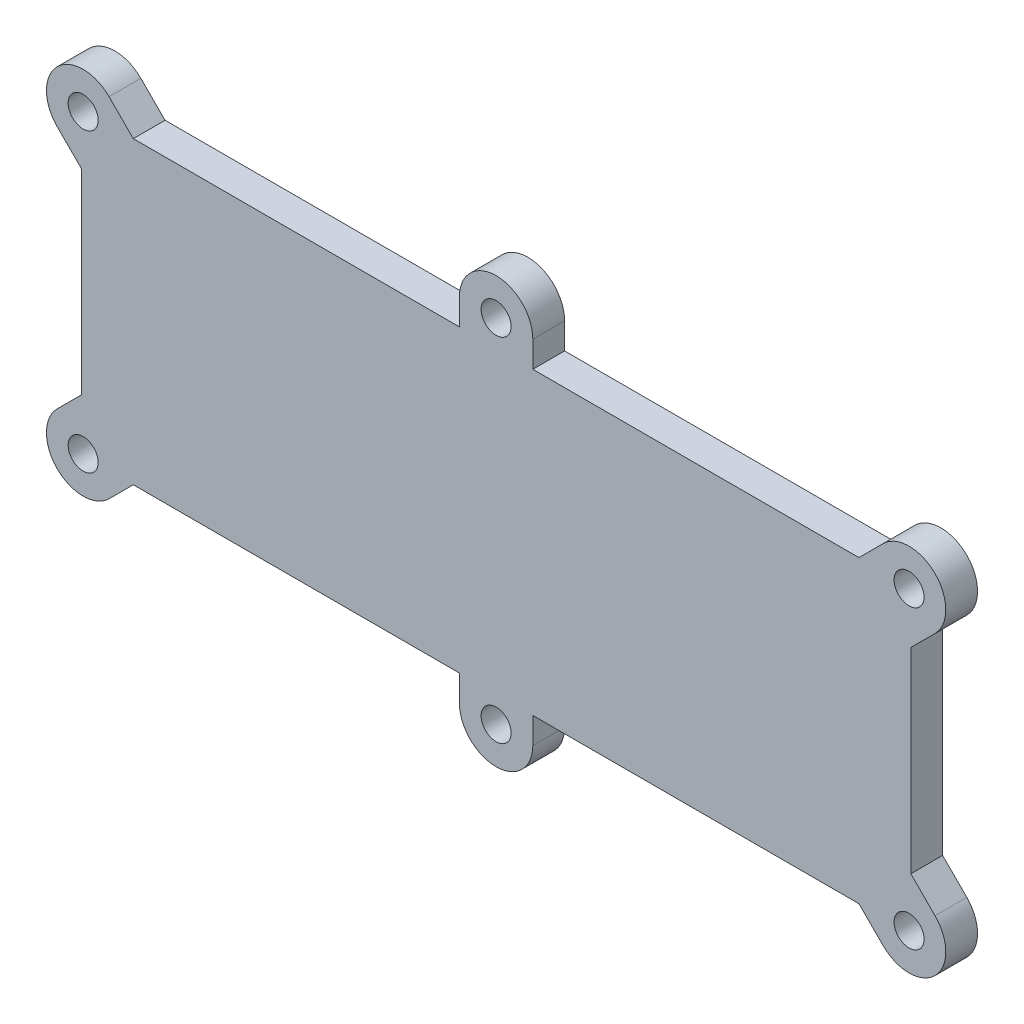
from build123d import *

# Parameters (mm, degrees)
BOSS_EXTRUDE1_DEPTH  = 4.7625
M4_CLEARANCE_HOLE1_D = 4.5


with BuildPart() as part:
    # Sketch1 → Boss-Extrude1 (new body)
    with BuildSketch(Plane.XY):
        with BuildLine():
            Line((166.110631803, -43.351929971), (117.238806396, -43.351929971))
            Line((117.238806396, -43.351929971), (117.238806396, -39.442229971))
            ThreePointArc((117.238806396, -39.442229971), (111.738806396, -33.942229971), (106.238806396, -39.442229971))
            Line((106.238806396, -39.442229971), (106.238806396, -43.351929971))
            Line((106.238806396, -43.351929971), (57.366980989, -43.351929971))
            Line((57.366980989, -43.351929971), (53.740076833, -39.725025815))
            ThreePointArc((53.740076833, -39.725025815), (45.96190224, -39.725025815), (45.96190224, -47.503200408))
            Line((45.96190224, -47.503200408), (49.588806396, -51.130104564))
            Line((49.588806396, -51.130104564), (49.588806396, -80.498755377))
            Line((49.588806396, -80.498755377), (45.96190224, -84.125659533))
            ThreePointArc((45.96190224, -84.125659533), (45.96190224, -91.903834126), (53.740076833, -91.903834126))
            Line((53.740076833, -91.903834126), (57.366980989, -88.276929971))
            Line((57.366980989, -88.276929971), (106.238806396, -88.276929971))
            Line((106.238806396, -88.276929971), (106.238806396, -92.186629971))
            ThreePointArc((106.238806396, -92.186629971), (111.738806396, -97.686629971), (117.238806396, -92.186629971))
            Line((117.238806396, -92.186629971), (117.238806396, -88.276929971))
            Line((117.238806396, -88.276929971), (166.110631803, -88.276929971))
            Line((166.110631803, -88.276929971), (169.737535958, -91.903834126))
            ThreePointArc((169.737535958, -91.903834126), (177.515710552, -91.903834126), (177.515710552, -84.125659533))
            Line((177.515710552, -84.125659533), (173.888806396, -80.498755377))
            Line((173.888806396, -80.498755377), (173.888806396, -51.130104564))
            Line((173.888806396, -51.130104564), (177.515710552, -47.503200408))
            ThreePointArc((177.515710552, -47.503200408), (177.515710552, -39.725025815), (169.737535958, -39.725025815))
            Line((169.737535958, -39.725025815), (166.110631803, -43.351929971))
        make_face()
    extrude(amount=BOSS_EXTRUDE1_DEPTH)

    # M4 Clearance Hole1 (through all)
    with Locations(Plane.XY.offset(4.7625)):
        with Locations((111.738806396, -39.442229971), (173.626623255, -43.614113111), (173.626623255, -88.01474683), (111.738806396, -92.186629971), (49.850989537, -88.01474683), (49.850989537, -43.614113111)):
            Hole(M4_CLEARANCE_HOLE1_D / 2)


solid = part.part
